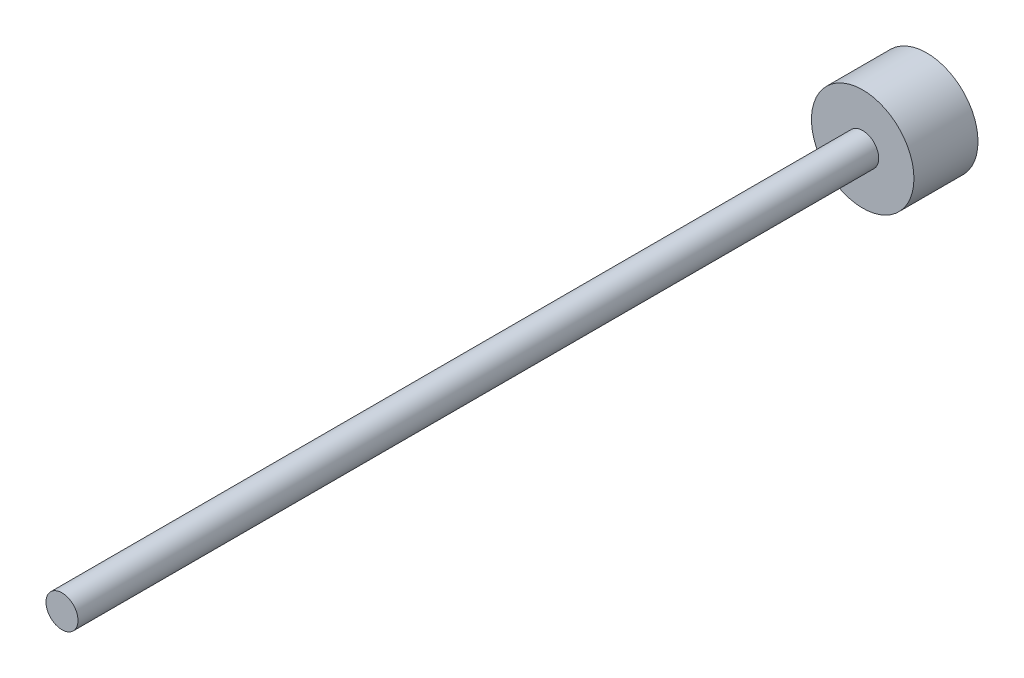
from build123d import *

# Parameters (mm, degrees)
SKETCH_1_R      = 8
EXTRUDE_1_DEPTH = 10
SKETCH_2_R      = 2.5
EXTRUDE_2_DEPTH = 125


with BuildPart() as part:
    # 草图1 → 凸台-拉伸1 (new body)
    with BuildSketch(Plane.XY):
        Circle(SKETCH_1_R)
    extrude(amount=EXTRUDE_1_DEPTH)

    # 草图2 → 凸台-拉伸2 (add)
    with BuildSketch(Plane.XY.offset(10)):
        Circle(SKETCH_2_R)
    extrude(amount=EXTRUDE_2_DEPTH)


solid = part.part
